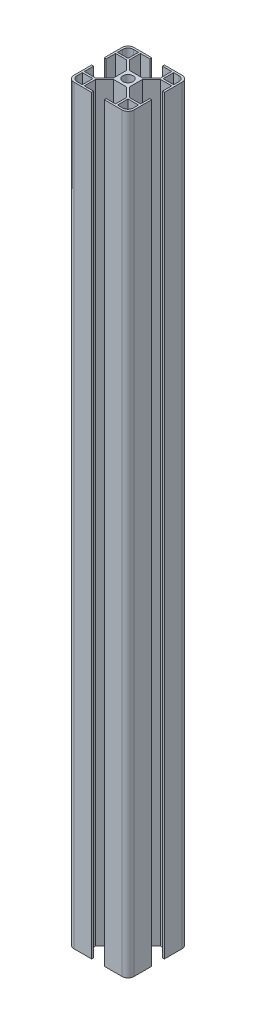
from build123d import *

# Parameters (mm, degrees)
SKETCH_1_W      = 6.2
SKETCH_1_H      = 1.3
SKETCH_1_W_2    = 1.3
SKETCH_1_H_2    = 6.2
SKETCH_1_W_3    = 10.5
SKETCH_1_H_3    = 10.5
SKETCH_1_R      = 3.4
EXTRUDE_2_DEPTH = 500


with BuildPart() as part:
    # 草图1 → 凸台-拉伸2 (new body)
    with BuildSketch(Plane(origin=(0, 0, 0), x_dir=(1, 0, 0), z_dir=(0, 1, 0))):
        with Locations((-7.3, -19.35)):
            Rectangle(SKETCH_1_W, SKETCH_1_H)
        with BuildLine():
            Line((-18.7, -10.4), (-20, -10.4))
            Line((-20, -10.4), (-20, -16.079155302))
            ThreePointArc((-20, -16.079155302), (-18.851611176, -18.851611176), (-16.079155302, -20))
            Line((-16.079155302, -20), (-10.4, -20))
            Line((-10.4, -20), (-10.4, -18.7))
            Line((-10.4, -18.7), (-10.4, -11.319238816))
            Line((-10.4, -11.319238816), (-10.4, -10.4))
            Line((-10.4, -10.4), (-11.319238816, -10.4))
            Line((-11.319238816, -10.4), (-18.7, -10.4))
        make_face()
        Polygon((-18.7, -15.2), (-18.7, -11.7), (-15.2, -11.7), (-11.7, -11.7), (-11.7, -15.2), (-11.7, -18.7), (-15.2, -18.7), (-18.7, -18.7), align=None, mode=Mode.SUBTRACT)
        with Locations((-19.35, -7.3)):
            Rectangle(SKETCH_1_W_2, SKETCH_1_H_2)
        with BuildLine():
            ThreePointArc((-15.2, -18.7), (-17.674873734, -17.674873734), (-18.7, -15.2))
            Line((-18.7, -15.2), (-18.7, -18.7))
            Line((-18.7, -18.7), (-15.2, -18.7))
        make_face()
        Polygon((-5.25, -5.25), (-5.25, -4.330761184), (-11.319238816, -10.4), (-10.4, -10.4), (-10.4, -11.319238816), (-4.330761184, -5.25), align=None)
        Rectangle(SKETCH_1_W_3, SKETCH_1_H_3)
        with Locations(Location((0, 0, 0), (0, 0, 270))):
            Circle(SKETCH_1_R, mode=Mode.SUBTRACT)
        Polygon((11.319238816, -10.4), (5.25, -4.330761184), (5.25, -5.25), (4.330761184, -5.25), (10.4, -11.319238816), (10.4, -10.4), align=None)
        Polygon((10.4, 11.319238816), (4.330761184, 5.25), (5.25, 5.25), (5.25, 4.330761184), (11.319238816, 10.4), (10.4, 10.4), align=None)
        Polygon((-4.330761184, 5.25), (-10.4, 11.319238816), (-10.4, 10.4), (-11.319238816, 10.4), (-5.25, 4.330761184), (-5.25, 5.25), align=None)
        with BuildLine():
            Line((18.7, -10.4), (11.319238816, -10.4))
            Line((11.319238816, -10.4), (10.4, -10.4))
            Line((10.4, -10.4), (10.4, -11.319238816))
            Line((10.4, -11.319238816), (10.4, -18.7))
            Line((10.4, -18.7), (10.4, -20))
            Line((10.4, -20), (16.079155302, -20))
            ThreePointArc((16.079155302, -20), (18.851611176, -18.851611176), (20, -16.079155302))
            Line((20, -16.079155302), (20, -10.4))
            Line((20, -10.4), (18.7, -10.4))
        make_face()
        Polygon((15.2, -11.7), (18.7, -11.7), (18.7, -15.2), (18.7, -18.7), (15.2, -18.7), (11.7, -18.7), (11.7, -15.2), (11.7, -11.7), align=None, mode=Mode.SUBTRACT)
        with BuildLine():
            Line((18.7, -18.7), (18.7, -15.2))
            ThreePointArc((18.7, -15.2), (17.674873734, -17.674873734), (15.2, -18.7))
            Line((15.2, -18.7), (18.7, -18.7))
        make_face()
        with BuildLine():
            Line((16.079155302, 20), (10.4, 20))
            Line((10.4, 20), (10.4, 18.7))
            Line((10.4, 18.7), (10.4, 11.319238816))
            Line((10.4, 11.319238816), (10.4, 10.4))
            Line((10.4, 10.4), (11.319238816, 10.4))
            Line((11.319238816, 10.4), (18.7, 10.4))
            Line((18.7, 10.4), (20, 10.4))
            Line((20, 10.4), (20, 16.079155302))
            ThreePointArc((20, 16.079155302), (18.851611176, 18.851611176), (16.079155302, 20))
        make_face()
        Polygon((15.2, 18.7), (18.7, 18.7), (18.7, 15.2), (18.7, 11.7), (15.2, 11.7), (11.7, 11.7), (11.7, 15.2), (11.7, 18.7), align=None, mode=Mode.SUBTRACT)
        with BuildLine():
            Line((18.7, 15.2), (18.7, 18.7))
            Line((18.7, 18.7), (15.2, 18.7))
            ThreePointArc((15.2, 18.7), (17.674873734, 17.674873734), (18.7, 15.2))
        make_face()
        with BuildLine():
            Line((-10.4, 20), (-16.079155302, 20))
            ThreePointArc((-16.079155302, 20), (-18.851611176, 18.851611176), (-20, 16.079155302))
            Line((-20, 16.079155302), (-20, 10.4))
            Line((-20, 10.4), (-18.7, 10.4))
            Line((-18.7, 10.4), (-11.319238816, 10.4))
            Line((-11.319238816, 10.4), (-10.4, 10.4))
            Line((-10.4, 10.4), (-10.4, 11.319238816))
            Line((-10.4, 11.319238816), (-10.4, 18.7))
            Line((-10.4, 18.7), (-10.4, 20))
        make_face()
        Polygon((-15.2, 11.7), (-18.7, 11.7), (-18.7, 15.2), (-18.7, 18.7), (-15.2, 18.7), (-11.7, 18.7), (-11.7, 15.2), (-11.7, 11.7), align=None, mode=Mode.SUBTRACT)
        with BuildLine():
            Line((-18.7, 18.7), (-18.7, 15.2))
            ThreePointArc((-18.7, 15.2), (-17.674873734, 17.674873734), (-15.2, 18.7))
            Line((-15.2, 18.7), (-18.7, 18.7))
        make_face()
        with Locations((-7.3, 19.35)):
            Rectangle(SKETCH_1_W, SKETCH_1_H)
        with Locations((7.3, 19.35)):
            Rectangle(SKETCH_1_W, SKETCH_1_H)
        with Locations((19.35, 7.3)):
            Rectangle(SKETCH_1_W_2, SKETCH_1_H_2)
        with Locations((-19.35, 7.3)):
            Rectangle(SKETCH_1_W_2, SKETCH_1_H_2)
        with Locations((19.35, -7.3)):
            Rectangle(SKETCH_1_W_2, SKETCH_1_H_2)
        with Locations((7.3, -19.35)):
            Rectangle(SKETCH_1_W, SKETCH_1_H)
    extrude(amount=EXTRUDE_2_DEPTH)


solid = part.part
